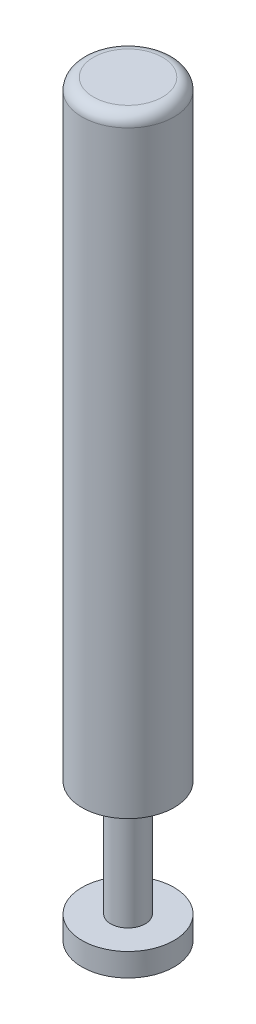
from build123d import *

# Parameters (mm, degrees)
SKETCH_1_R          = 2
EXTRUDE_1_DEPTH     = 32.5
CUT_EXTRUDE_START   = -1
SKETCH_2_R          = 2
SKETCH_2_R_2        = 0.75
CUT_EXTRUDE_1_DEPTH = 5
FILLET_1_R          = 0.5


with BuildPart() as part:
    # ｽｹｯﾁ1 → ﾎﾞｽ - 押し出し1 (new body)
    with BuildSketch(Plane(origin=(0, 0, 0), x_dir=(1, 0, 0), z_dir=(0, 1, 0))):
        Circle(SKETCH_1_R)
    extrude(amount=EXTRUDE_1_DEPTH)

    # ｽｹｯﾁ2 → ｶｯﾄ - 押し出し1 (cut)
    with BuildSketch(Plane.XZ.offset(CUT_EXTRUDE_START)):
        Circle(SKETCH_2_R)
        Circle(SKETCH_2_R_2, mode=Mode.SUBTRACT)
    extrude(amount=-CUT_EXTRUDE_1_DEPTH, mode=Mode.SUBTRACT)

    # ﾌｨﾚｯﾄ1
    fillet_1_edges = [part.edges().sort_by_distance(p)[0] for p in [
        (-2, 32.5, 0),
    ]]
    fillet(fillet_1_edges, radius=FILLET_1_R)


solid = part.part
